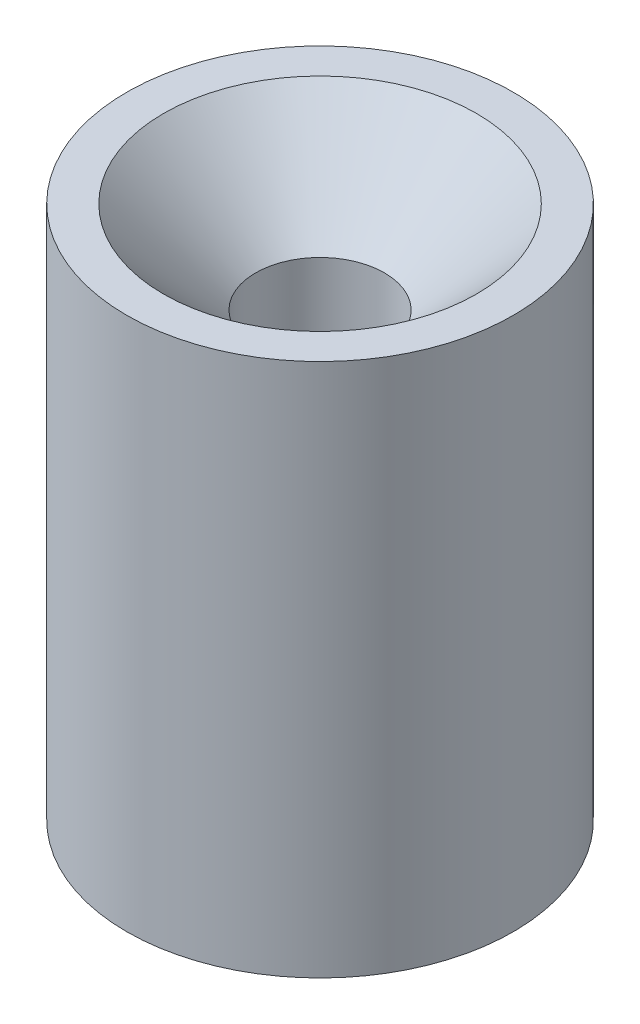
from build123d import *

# Parameters (mm, degrees)
SKETCH1_R                    = 21
BOSS_EXTRUDE1_DEPTH          = 24
BOSS_EXTRUDE1_DEPTH_BACK     = 24
SKETCH3_R                    = 7
CUT_EXTRUDE1_DEPTH           = 24
CUT_EXTRUDE1_TAPER           = -15
CUT_EXTRUDE1_OTHER_WAY_DEPTH = 24
SKETCH4_R                    = 21
BOSS_EXTRUDE2_DEPTH          = 10
SKETCH5_R                    = 7
CUT_EXTRUDE2_DEPTH           = 10
CUT_EXTRUDE2_TAPER           = -45


with BuildPart() as part:
    # Sketch1 → Boss-Extrude1 (new body, two sides)
    with BuildSketch(Plane(origin=(0, 0, 0), x_dir=(1, 0, 0), z_dir=(0, 1, 0))) as boss_extrude1_sk:
        Circle(SKETCH1_R)
    extrude(amount=BOSS_EXTRUDE1_DEPTH)
    extrude(boss_extrude1_sk.sketch, amount=-BOSS_EXTRUDE1_DEPTH_BACK)

    # Sketch3 → Cut-Extrude1 (cut)
    with BuildSketch(Plane(origin=(0, 0, 0), x_dir=(1, 0, 0), z_dir=(0, 1, 0))):
        Circle(SKETCH3_R)
    extrude(amount=-CUT_EXTRUDE1_DEPTH, taper=CUT_EXTRUDE1_TAPER, mode=Mode.SUBTRACT)

    # Sketch3 → Cut-Extrude1 other way (cut)
    with BuildSketch(Plane(origin=(0, 0, 0), x_dir=(1, 0, 0), z_dir=(0, 1, 0))):
        Circle(SKETCH3_R)
    extrude(amount=CUT_EXTRUDE1_OTHER_WAY_DEPTH, mode=Mode.SUBTRACT)

    # Sketch4 → Boss-Extrude2 (add)
    with BuildSketch(Plane(origin=(0, 24, 0), x_dir=(1, 0, 0), z_dir=(0, 1, 0))):
        Circle(SKETCH4_R)
    extrude(amount=BOSS_EXTRUDE2_DEPTH)

    # Sketch5 → Cut-Extrude2 (cut)
    with BuildSketch(Plane.XZ.offset(-24)):
        Circle(SKETCH5_R)
    extrude(amount=-CUT_EXTRUDE2_DEPTH, taper=CUT_EXTRUDE2_TAPER, mode=Mode.SUBTRACT)


solid = part.part
